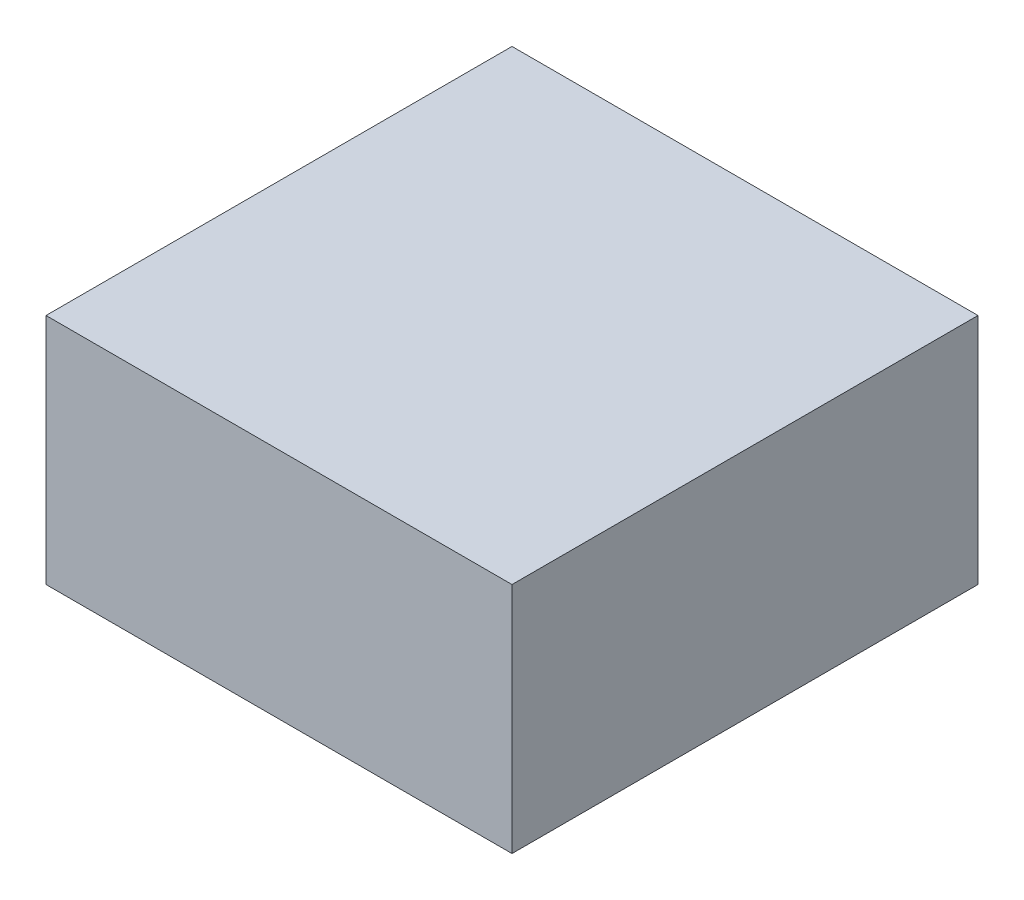
from build123d import *

# Parameters (mm, degrees)
SKETCH1_W           = 18
SKETCH1_H           = 18
BOSS_EXTRUDE1_DEPTH = 9


with BuildPart() as part:
    # Sketch1 → Boss-Extrude1 (new body)
    with BuildSketch(Plane(origin=(0, 0, 0), x_dir=(1, 0, 0), z_dir=(0, 1, 0))):
        with Locations((9, 9)):
            Rectangle(SKETCH1_W, SKETCH1_H)
    extrude(amount=BOSS_EXTRUDE1_DEPTH)


solid = part.part
